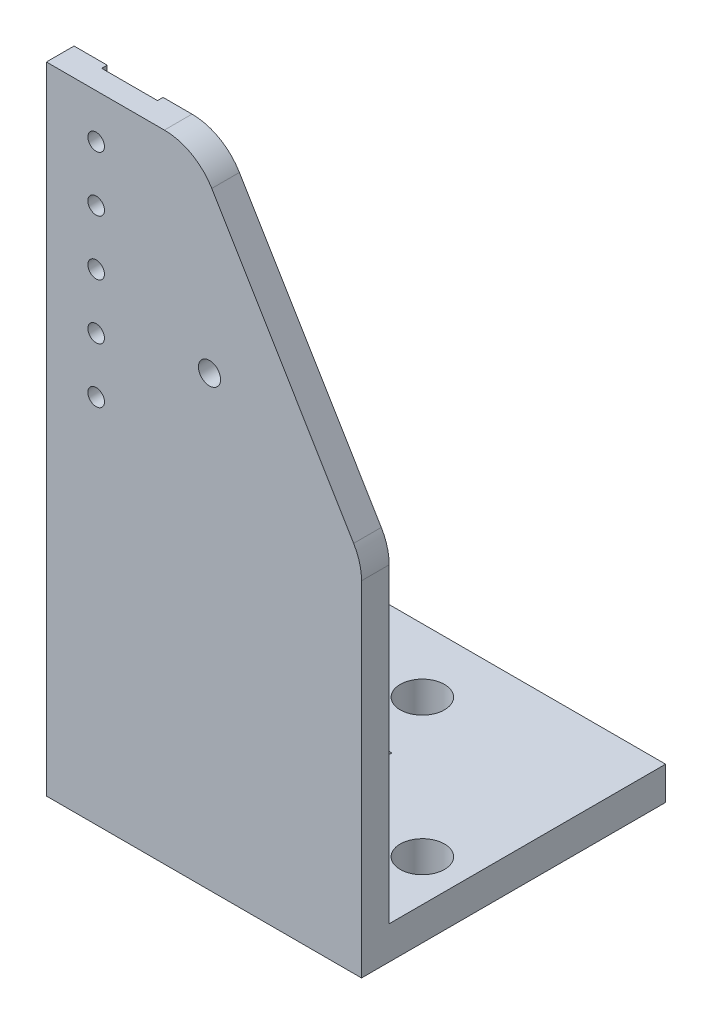
from build123d import *

# Parameters (mm, degrees)
SKETCH_1_W                 = 40
SKETCH_1_H                 = 10
SKETCH_1_H_2               = 15
EXTRUDE_1_DEPTH            = 6
SKETCH_3_R                 = 3
SKETCH_3_R_2               = 4
CUT_EXTRUDE_1_DEPTH        = 7
SKETCH_4_W                 = 15
SKETCH_4_H                 = 26
CUT_EXTRUDE_2_DEPTH        = 1
SKETCH_6_R                 = 2
EXTRUDE_2_DEPTH            = 5
SKETCH_7_R                 = 1.5
CUT_EXTRUDE_4_DEPTH        = 6
SKETCH_9_R                 = 6
CUT_EXTRUDE_6_DEPTH        = 2
SKETCH_10_W                = 65
SKETCH_10_H                = 15
EXTRUDE_3_DEPTH            = 6
SKETCH_11_R                = 4
CUT_EXTRUDE_7_DEPTH        = 6
SKETCH_12_W                = 94.112521104
SKETCH_12_H                = 159.87509758
CUT_EXTRUDE_8_DEPTH        = 8
CHAMFER_1_SIZE             = 50
CHAMFER_1_SIZE2            = 30
FILLET_1_R                 = 10
EXTRUDE_4_DEPTH            = 5
FILLET_2_R                 = 10
SKETCH_14_W                = 10.1
SKETCH_14_H                = 55
SKETCH_14_R                = 1.5
CUT_EXTRUDE_9_DEPTH        = 1
PATTERN_LINEAR_1_COUNT     = 3
PATTERN_LINEAR_1_PITCH     = 10
PATTERN_LINEAR_1_COL_COUNT = 3
PATTERN_LINEAR_1_COL_PITCH = 10


with BuildPart() as part:
    # 草图1 → 凸台-拉伸1 (new body)
    with BuildSketch(Plane(origin=(0, 0, 0), x_dir=(1, 0, 0), z_dir=(0, 1, 0))):
        with Locations((20, -5)):
            Rectangle(SKETCH_1_W, SKETCH_1_H)
        with Locations((20, 7.5)):
            Rectangle(SKETCH_1_W, SKETCH_1_H_2)
        with Locations((20, -15)):
            Rectangle(SKETCH_1_W, SKETCH_1_H)
        Polygon((-20, 15), (-20, -20), (0, -20), (0, -10), (0, 0), (0, 15), align=None)
        Polygon((45, -20), (40, -20), (40, -10), (40, 0), (40, 15), (45, 15), align=None)
    extrude(amount=EXTRUDE_1_DEPTH)

    # 草图3 → 切除-拉伸1 (cut, through all)
    with BuildSketch(Plane(origin=(0, 6, 0), x_dir=(1, 0, 0), z_dir=(0, 1, 0))):
        with Locations((12.5, -6.5)):
            Circle(SKETCH_3_R)
        with Locations((37.5, -6.5)):
            Circle(SKETCH_3_R_2)
    extrude(amount=-CUT_EXTRUDE_1_DEPTH, mode=Mode.SUBTRACT)

    # 草图4 → 切除-拉伸2 (cut)
    with BuildSketch(Plane(origin=(0, 6, 0), x_dir=(1, 0, 0), z_dir=(0, 1, 0))):
        with Locations((11, -6)):
            Rectangle(SKETCH_4_W, SKETCH_4_H)
    extrude(amount=-CUT_EXTRUDE_2_DEPTH, mode=Mode.SUBTRACT)

    # 草图6 → 凸台-拉伸2 (add)
    with BuildSketch(Plane.XY.offset(20)):
        Polygon((-20, 0), (12.5, 0), (45, 0), (45, 115), (-20, 115), align=None)
        with Locations((17.5, 81)):
            Circle(SKETCH_6_R, mode=Mode.SUBTRACT)
    extrude(amount=EXTRUDE_2_DEPTH)

    # 草图7 → 切除-拉伸4 (cut, through all)
    with BuildSketch(Plane(origin=(0, 0, 20), x_dir=(-1, 0, 0), z_dir=(0, 0, -1))):
        with Locations((3, 87)):
            Circle(SKETCH_7_R)
    cut_extrude_4 = extrude(amount=-CUT_EXTRUDE_4_DEPTH, mode=Mode.SUBTRACT)

    # 草图9 → 切除-拉伸6 (cut)
    with BuildSketch(Plane.XZ):
        with Locations((12.5, 6.5)):
            Circle(SKETCH_9_R)
    extrude(amount=-CUT_EXTRUDE_6_DEPTH, mode=Mode.SUBTRACT)

    # 草图10 → 凸台-拉伸3 (add)
    with BuildSketch(Plane.XZ):
        with Locations((12.5, -22.5)):
            Rectangle(SKETCH_10_W, SKETCH_10_H)
    extrude(amount=-EXTRUDE_3_DEPTH)

    # 草图11 → 切除-拉伸7 (cut)
    with BuildSketch(Plane(origin=(0, 6, 0), x_dir=(1, 0, 0), z_dir=(0, 1, 0))):
        with Locations((12.5, 18.5)):
            Circle(SKETCH_11_R)
    extrude(amount=-CUT_EXTRUDE_7_DEPTH, mode=Mode.SUBTRACT)

    # 草图12 → 切除-拉伸8 (cut)
    with BuildSketch(Plane.ZY.offset(20)):
        with Locations((-11.795063813, 76.080369624)):
            Rectangle(SKETCH_12_W, SKETCH_12_H)
    extrude(amount=-CUT_EXTRUDE_8_DEPTH, mode=Mode.SUBTRACT)

    # 倒角1
    chamfer_1_edges = [part.edges().sort_by_distance(p)[0] for p in [
        (45, 115, 22.5),
    ]]
    chamfer_1_side = [part.faces().sort_by_distance(p)[0] for p in [
        (45, 60.5, 21.274754878),
    ]]
    chamfer(chamfer_1_edges, length=CHAMFER_1_SIZE, length2=CHAMFER_1_SIZE2, reference=chamfer_1_side[0])

    # 圆角1
    fillet_1_edges = [part.edges().sort_by_distance(p)[0] for p in [
        (15, 115, 22.5),
        (45, 65, 22.5),
    ]]
    fillet(fillet_1_edges, radius=FILLET_1_R)

    # 草图13 → 凸台-拉伸4 (add)
    with BuildSketch(Plane.ZY.offset(12)):
        Polygon((20, 6), (0, 6), (20, 46), align=None)
    extrude(amount=-EXTRUDE_4_DEPTH)

    # 圆角2
    fillet_2_edges = [part.edges().sort_by_distance(p)[0] for p in [
        (-9.5, 46, 20),
        (-9.5, 6, 0),
    ]]
    fillet(fillet_2_edges, radius=FILLET_2_R)

    # 草图14 → 切除-拉伸9 (cut)
    with BuildSketch(Plane(origin=(0, 0, 20), x_dir=(-1, 0, 0), z_dir=(0, 0, -1))):
        with Locations((0.95, 87.5)):
            Rectangle(SKETCH_14_W, SKETCH_14_H)
        with Locations((3, 87)):
            Circle(SKETCH_14_R, mode=Mode.SUBTRACT)
    extrude(amount=-CUT_EXTRUDE_9_DEPTH, mode=Mode.SUBTRACT)

    # 阵列(线性)1: 切除-拉伸4 ×3
    with Locations(*[(0, -i * PATTERN_LINEAR_1_PITCH, 0) for i in range(1, PATTERN_LINEAR_1_COUNT)]):
        add(cut_extrude_4, mode=Mode.SUBTRACT)

    # 阵列(线性)1 col: 切除-拉伸4 ×3
    with Locations(*[(0, i * PATTERN_LINEAR_1_COL_PITCH, 0) for i in range(1, PATTERN_LINEAR_1_COL_COUNT)]):
        add(cut_extrude_4, mode=Mode.SUBTRACT)


solid = part.part
